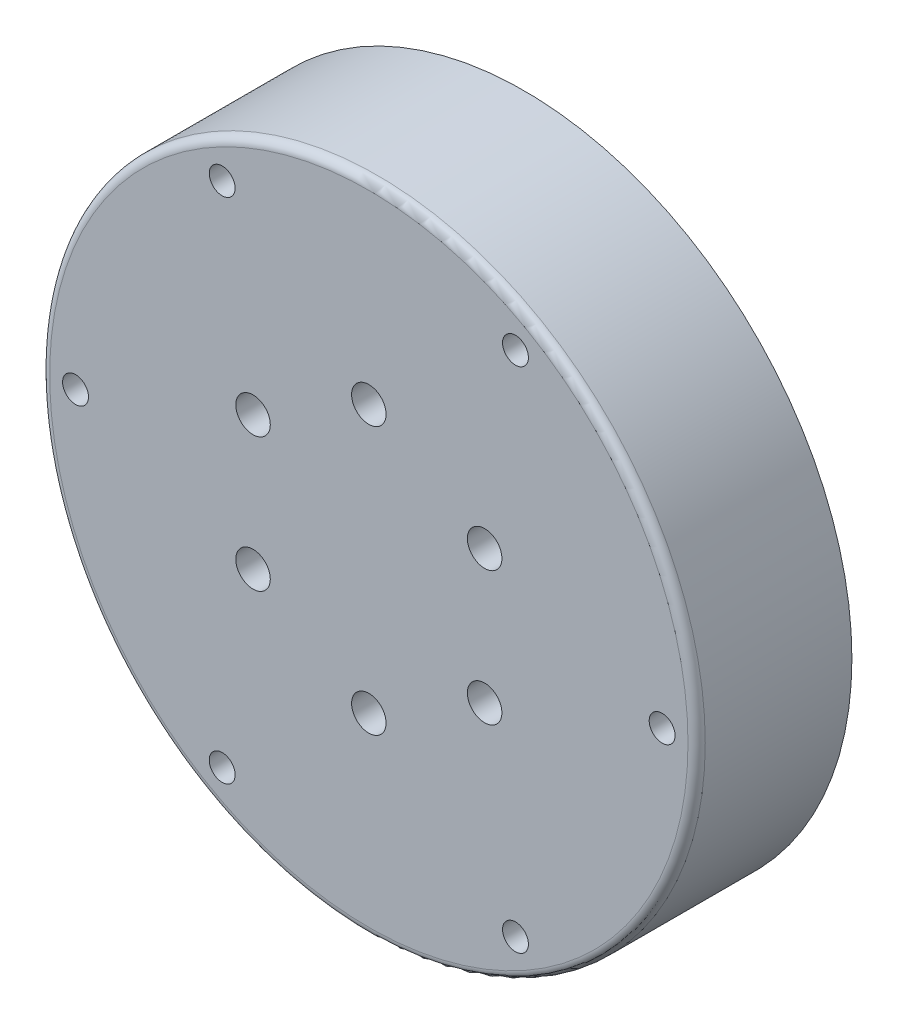
from build123d import *

# Parameters (mm, degrees)
SKETCH_1_R          = 38
EXTRUDE_1_DEPTH     = 18
CUT_EXTRUDE_1_REACH = 20
SKETCH_2_R          = 1.5
CUT_EXTRUDE_2_DEPTH = 12.5
FILLET_1_R          = 1
CUT_EXTRUDE_7_REACH = 13
SKETCH_6_W          = 20
SKETCH_6_H          = 4
CUT_EXTRUDE_8_REACH = 20
SKETCH_7_R          = 2


with BuildPart() as part:
    # Эскиз1 → Бобышка-Вытянуть1 (new body)
    with BuildSketch(Plane.XY):
        Circle(SKETCH_1_R)
    extrude(amount=EXTRUDE_1_DEPTH)

    # Эскиз2 → Вырез-Вытянуть1 (cut, up to next)
    with BuildSketch(Plane.XY.offset(18), mode=Mode.PRIVATE) as cut_extrude_1_sk1:
        with Locations((-34, 0)):
            Circle(SKETCH_2_R)
    cut_extrude_1_tool1 = extrude(cut_extrude_1_sk1.sketch, amount=-CUT_EXTRUDE_1_REACH, mode=Mode.PRIVATE) & part.part
    add(cut_extrude_1_tool1.solids().sort_by_distance((-34, 0, 18))[0], mode=Mode.SUBTRACT)
    # Эскиз2 → Вырез-Вытянуть1 (cut, up to next)
    with BuildSketch(Plane.XY.offset(18), mode=Mode.PRIVATE) as cut_extrude_1_sk2:
        with Locations((-17, 29.444863729)):
            Circle(SKETCH_2_R)
    cut_extrude_1_tool2 = extrude(cut_extrude_1_sk2.sketch, amount=-CUT_EXTRUDE_1_REACH, mode=Mode.PRIVATE) & part.part
    add(cut_extrude_1_tool2.solids().sort_by_distance((-17, 29.444864, 18))[0], mode=Mode.SUBTRACT)
    # Эскиз2 → Вырез-Вытянуть1 (cut, up to next)
    with BuildSketch(Plane.XY.offset(18), mode=Mode.PRIVATE) as cut_extrude_1_sk3:
        with Locations((17, 29.444863729)):
            Circle(SKETCH_2_R)
    cut_extrude_1_tool3 = extrude(cut_extrude_1_sk3.sketch, amount=-CUT_EXTRUDE_1_REACH, mode=Mode.PRIVATE) & part.part
    add(cut_extrude_1_tool3.solids().sort_by_distance((17, 29.444864, 18))[0], mode=Mode.SUBTRACT)
    # Эскиз2 → Вырез-Вытянуть1 (cut, up to next)
    with BuildSketch(Plane.XY.offset(18), mode=Mode.PRIVATE) as cut_extrude_1_sk4:
        with Locations((34, 0)):
            Circle(SKETCH_2_R)
    cut_extrude_1_tool4 = extrude(cut_extrude_1_sk4.sketch, amount=-CUT_EXTRUDE_1_REACH, mode=Mode.PRIVATE) & part.part
    add(cut_extrude_1_tool4.solids().sort_by_distance((34, 0, 18))[0], mode=Mode.SUBTRACT)
    # Эскиз2 → Вырез-Вытянуть1 (cut, up to next)
    with BuildSketch(Plane.XY.offset(18), mode=Mode.PRIVATE) as cut_extrude_1_sk5:
        with Locations((17, -29.444863729)):
            Circle(SKETCH_2_R)
    cut_extrude_1_tool5 = extrude(cut_extrude_1_sk5.sketch, amount=-CUT_EXTRUDE_1_REACH, mode=Mode.PRIVATE) & part.part
    add(cut_extrude_1_tool5.solids().sort_by_distance((17, -29.444864, 18))[0], mode=Mode.SUBTRACT)
    # Эскиз2 → Вырез-Вытянуть1 (cut, up to next)
    with BuildSketch(Plane.XY.offset(18), mode=Mode.PRIVATE) as cut_extrude_1_sk6:
        with Locations((-17, -29.444863729)):
            Circle(SKETCH_2_R)
    cut_extrude_1_tool6 = extrude(cut_extrude_1_sk6.sketch, amount=-CUT_EXTRUDE_1_REACH, mode=Mode.PRIVATE) & part.part
    add(cut_extrude_1_tool6.solids().sort_by_distance((-17, -29.444864, 18))[0], mode=Mode.SUBTRACT)

    # Эскиз3 → Вырез-Вытянуть2 (cut)
    with BuildSketch(Plane(origin=(0, 0, 0), x_dir=(-1, 0, 0), z_dir=(0, 0, -1))):
        with BuildLine():
            Line((-13.076696831, -27), (13.076696831, -27))
            ThreePointArc((13.076696831, -27), (0, 30), (-13.076696831, -27))
        make_face()
    extrude(amount=-CUT_EXTRUDE_2_DEPTH, mode=Mode.SUBTRACT)

    # Скругление1
    fillet_1_edges = [part.edges().sort_by_distance(p)[0] for p in [
        (-38, 0, 18),
    ]]
    fillet(fillet_1_edges, radius=FILLET_1_R)

    # Эскиз6 → Вырез-Вытянуть7 (cut, up to next)
    with BuildSketch(Plane(origin=(0, -27, 0), x_dir=(1, 0, 0), z_dir=(0, 1, 0)), mode=Mode.PRIVATE) as cut_extrude_7_sk1:
        with Locations((0, -10.5)):
            Rectangle(SKETCH_6_W, SKETCH_6_H)
    cut_extrude_7_tool1 = extrude(cut_extrude_7_sk1.sketch, amount=-CUT_EXTRUDE_7_REACH, mode=Mode.PRIVATE) & part.part
    add(cut_extrude_7_tool1.solids().sort_by_distance((0, -27, 10.5))[0], mode=Mode.SUBTRACT)

    # Эскиз7 → Вырез-Вытянуть8 (cut, up to next)
    with BuildSketch(Plane.XY.offset(18), mode=Mode.PRIVATE) as cut_extrude_8_sk1:
        with Locations((0, 15.5)):
            Circle(SKETCH_7_R)
    cut_extrude_8_tool1 = extrude(cut_extrude_8_sk1.sketch, amount=-CUT_EXTRUDE_8_REACH, mode=Mode.PRIVATE) & part.part
    add(cut_extrude_8_tool1.solids().sort_by_distance((0, 15.5, 18))[0], mode=Mode.SUBTRACT)
    # Эскиз7 → Вырез-Вытянуть8 (cut, up to next)
    with BuildSketch(Plane.XY.offset(18), mode=Mode.PRIVATE) as cut_extrude_8_sk2:
        with Locations((13.423393759, 7.75)):
            Circle(SKETCH_7_R)
    cut_extrude_8_tool2 = extrude(cut_extrude_8_sk2.sketch, amount=-CUT_EXTRUDE_8_REACH, mode=Mode.PRIVATE) & part.part
    add(cut_extrude_8_tool2.solids().sort_by_distance((13.423394, 7.75, 18))[0], mode=Mode.SUBTRACT)
    # Эскиз7 → Вырез-Вытянуть8 (cut, up to next)
    with BuildSketch(Plane.XY.offset(18), mode=Mode.PRIVATE) as cut_extrude_8_sk3:
        with Locations((13.423393759, -7.75)):
            Circle(SKETCH_7_R)
    cut_extrude_8_tool3 = extrude(cut_extrude_8_sk3.sketch, amount=-CUT_EXTRUDE_8_REACH, mode=Mode.PRIVATE) & part.part
    add(cut_extrude_8_tool3.solids().sort_by_distance((13.423394, -7.75, 18))[0], mode=Mode.SUBTRACT)
    # Эскиз7 → Вырез-Вытянуть8 (cut, up to next)
    with BuildSketch(Plane.XY.offset(18), mode=Mode.PRIVATE) as cut_extrude_8_sk4:
        with Locations((0, -15.5)):
            Circle(SKETCH_7_R)
    cut_extrude_8_tool4 = extrude(cut_extrude_8_sk4.sketch, amount=-CUT_EXTRUDE_8_REACH, mode=Mode.PRIVATE) & part.part
    add(cut_extrude_8_tool4.solids().sort_by_distance((0, -15.5, 18))[0], mode=Mode.SUBTRACT)
    # Эскиз7 → Вырез-Вытянуть8 (cut, up to next)
    with BuildSketch(Plane.XY.offset(18), mode=Mode.PRIVATE) as cut_extrude_8_sk5:
        with Locations((-13.423393759, -7.75)):
            Circle(SKETCH_7_R)
    cut_extrude_8_tool5 = extrude(cut_extrude_8_sk5.sketch, amount=-CUT_EXTRUDE_8_REACH, mode=Mode.PRIVATE) & part.part
    add(cut_extrude_8_tool5.solids().sort_by_distance((-13.423394, -7.75, 18))[0], mode=Mode.SUBTRACT)
    # Эскиз7 → Вырез-Вытянуть8 (cut, up to next)
    with BuildSketch(Plane.XY.offset(18), mode=Mode.PRIVATE) as cut_extrude_8_sk6:
        with Locations((-13.423393759, 7.75)):
            Circle(SKETCH_7_R)
    cut_extrude_8_tool6 = extrude(cut_extrude_8_sk6.sketch, amount=-CUT_EXTRUDE_8_REACH, mode=Mode.PRIVATE) & part.part
    add(cut_extrude_8_tool6.solids().sort_by_distance((-13.423394, 7.75, 18))[0], mode=Mode.SUBTRACT)


solid = part.part
